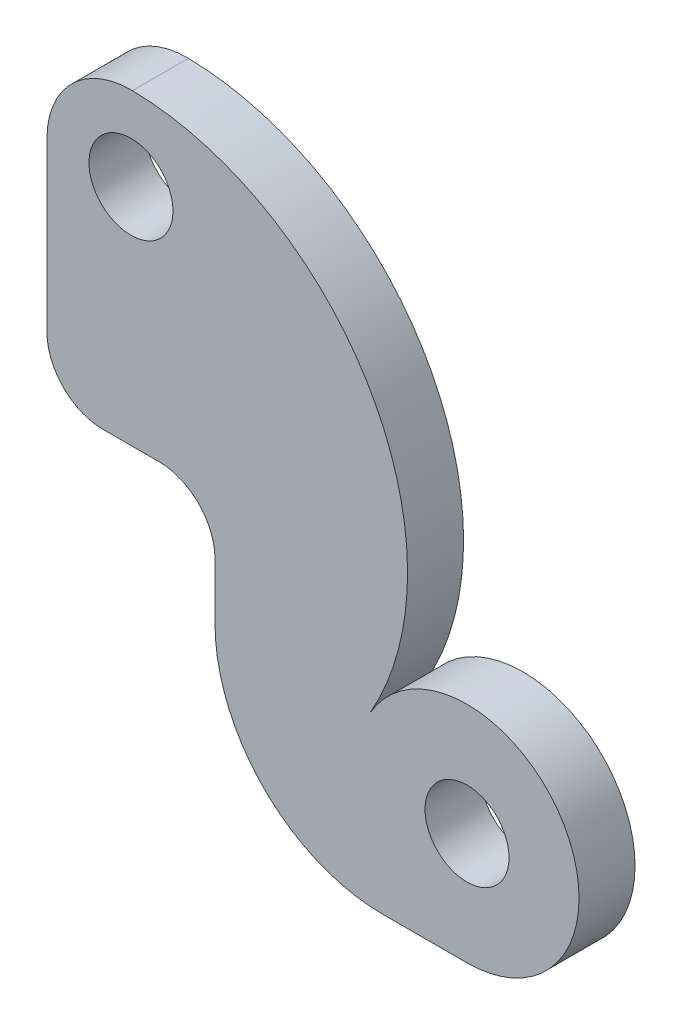
from build123d import *

# Parameters (mm, degrees)
SKETCH1_R           = 7.5
BOSS_EXTRUDE1_DEPTH = 5


with BuildPart() as part:
    # Sketch1 → Boss-Extrude1 (new body, symmetric)
    with BuildSketch(Plane.XY):
        with BuildLine():
            Line((-15, 0), (-15, -30))
            ThreePointArc((-15, -30), (-12.071067812, -37.071067812), (-5, -40))
            Line((-5, -40), (5, -40))
            ThreePointArc((5, -40), (12.071067812, -42.928932188), (15, -50))
            Line((15, -50), (15, -60))
            ThreePointArc((15, -60), (23.786796564, -81.213203436), (45, -90))
            Line((45, -90), (60, -90))
            ThreePointArc((60, -90), (77.320959018, -60.000781096), (42.680393915, -59.998437869))
            ThreePointArc((42.680393915, -59.998437869), (42.903012663, -10.380159149), (0.265123413, 14.997656803))
            ThreePointArc((0.265123413, 14.997656803), (-10.512448545, 10.699926429), (-15, 0))
        make_face()
        Circle(SKETCH1_R, mode=Mode.SUBTRACT)
        with Locations((60, -70)):
            Circle(SKETCH1_R, mode=Mode.SUBTRACT)
    extrude(amount=BOSS_EXTRUDE1_DEPTH, both=True)


solid = part.part
